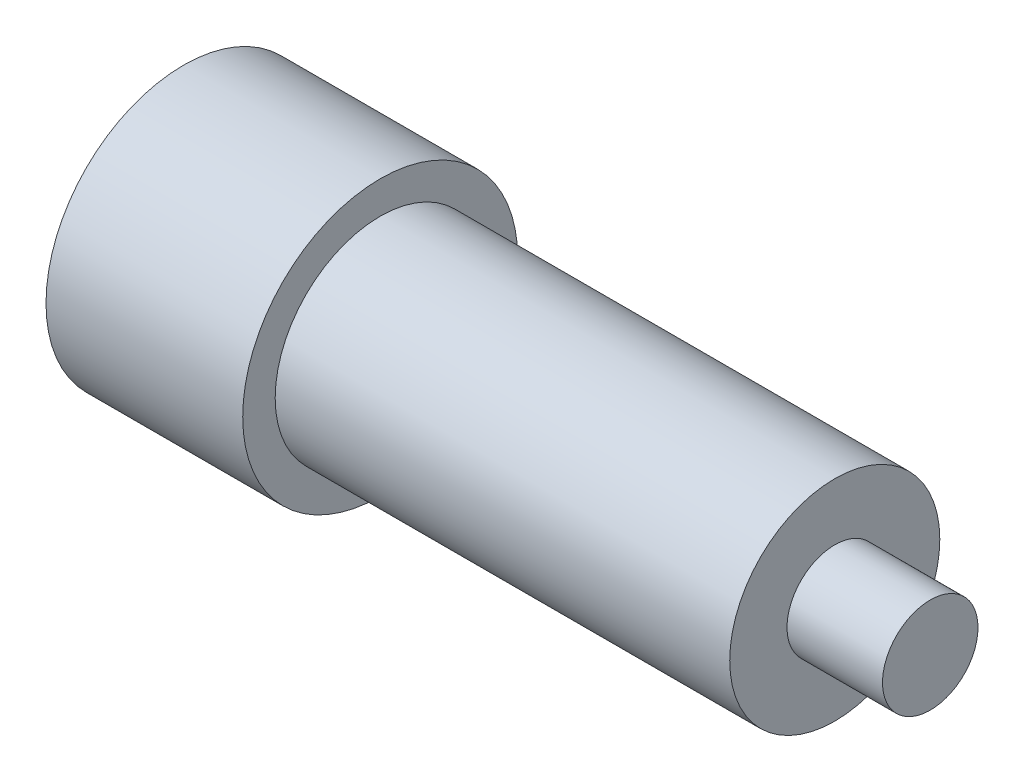
from build123d import *

# Parameters (mm, degrees)
SKETCH1_R           = 5.5
BOSS_EXTRUDE2_DEPTH = 23.8
SKETCH2_R           = 7.2
BOSS_EXTRUDE4_DEPTH = 10.3
SKETCH3_R           = 2.5
BOSS_EXTRUDE5_DEPTH = 5


with BuildPart() as part:
    # Sketch1 → Boss-Extrude2 (new body)
    with BuildSketch(Plane(origin=(0, 0, 0), x_dir=(0, 0, -1), z_dir=(1, 0, 0))):
        Circle(SKETCH1_R)
    extrude(amount=BOSS_EXTRUDE2_DEPTH)

    # Sketch2 → Boss-Extrude4 (add)
    with BuildSketch(Plane.ZY):
        Circle(SKETCH2_R)
    extrude(amount=BOSS_EXTRUDE4_DEPTH)

    # Sketch3 → Boss-Extrude5 (add)
    with BuildSketch(Plane(origin=(23.8, 0, 0), x_dir=(0, 0, -1), z_dir=(1, 0, 0))):
        Circle(SKETCH3_R)
    extrude(amount=BOSS_EXTRUDE5_DEPTH)


solid = part.part
